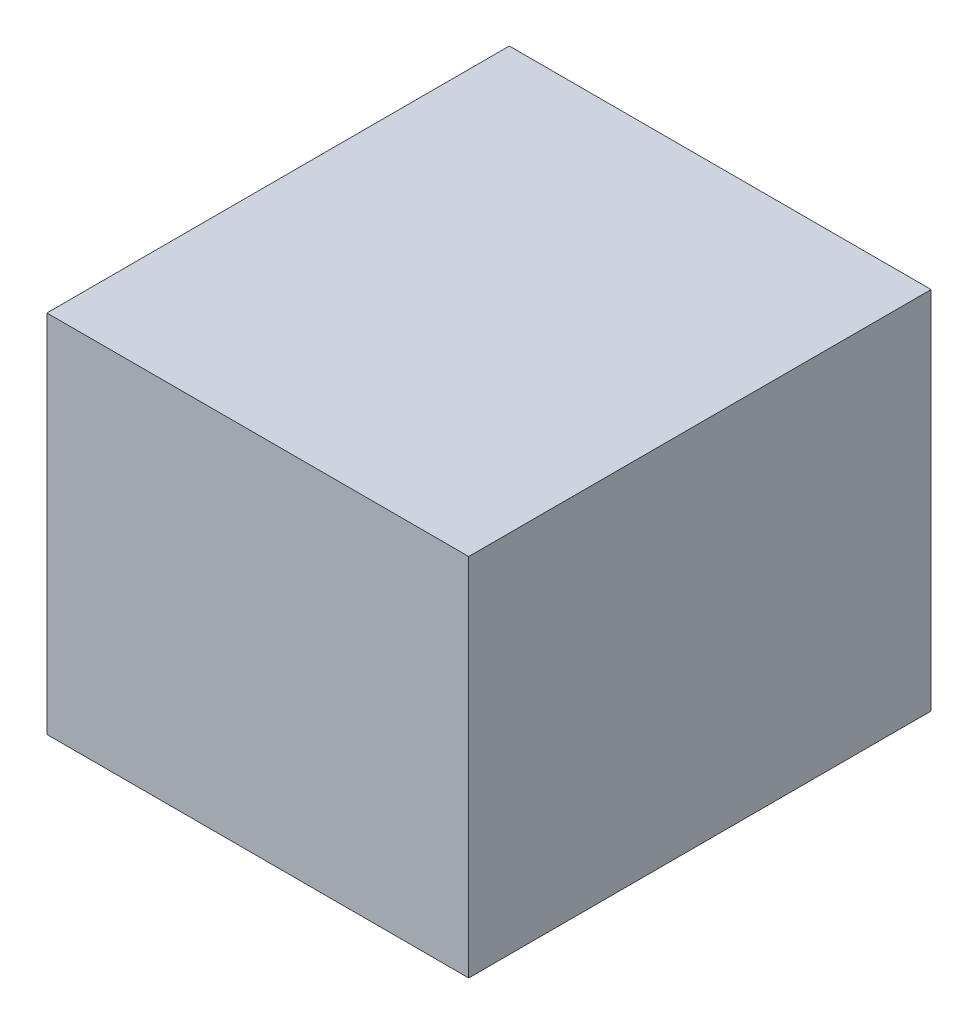
from build123d import *

# Parameters (mm, degrees)
SKETCH1_W           = 520
SKETCH1_H           = 450
BOSS_EXTRUDE1_DEPTH = 5
BOSS_EXTRUDE3_DEPTH = 560
SKETCH4_W           = 520
SKETCH4_H           = 450
BOSS_EXTRUDE4_DEPTH = 5
SKETCH5_W           = 520
SKETCH5_H           = 450
SKETCH5_W_2         = 510
SKETCH5_H_2         = 440
BOSS_EXTRUDE5_DEPTH = 100
SKETCH6_R           = 2.5
CUT_EXTRUDE1_DEPTH  = 10


with BuildPart() as part:
    # Sketch1 → Boss-Extrude1 (new body)
    with BuildSketch(Plane.XY):
        Rectangle(SKETCH1_W, SKETCH1_H)
    extrude(amount=BOSS_EXTRUDE1_DEPTH)

    # Sketch3 → Boss-Extrude3 (add)
    with BuildSketch(Plane(origin=(0, 0, 0), x_dir=(-1, 0, 0), z_dir=(0, 0, -1))):
        Polygon((260, 225), (-260, 225), (-260, -225), (-155, -225), (-155, -220), (-255, -220), (-255, 220), (255, 220), (255, -220), (155, -220), (155, -225), (260, -225), align=None)
    extrude(amount=BOSS_EXTRUDE3_DEPTH)

    # Sketch4 → Boss-Extrude4 (add)
    with BuildSketch(Plane(origin=(0, 0, -560), x_dir=(-1, 0, 0), z_dir=(0, 0, -1))):
        Rectangle(SKETCH4_W, SKETCH4_H)
    extrude(amount=BOSS_EXTRUDE4_DEPTH)

    # Sketch5 → Boss-Extrude5 (add)
    with BuildSketch(Plane.XY.offset(-560)):
        Rectangle(SKETCH5_W, SKETCH5_H)
        Rectangle(SKETCH5_W_2, SKETCH5_H_2, mode=Mode.SUBTRACT)
    extrude(amount=BOSS_EXTRUDE5_DEPTH)

    # Sketch6 → Cut-Extrude1 (cut)
    with BuildSketch(Plane.XZ.offset(225)):
        with Locations((-169.55, -10)):
            Circle(SKETCH6_R)
        with Locations((-169.55, -36)):
            Circle(SKETCH6_R)
        with Locations((-169.55, -450)):
            Circle(SKETCH6_R)
        with Locations((-169.55, -424)):
            Circle(SKETCH6_R)
    extrude(amount=-CUT_EXTRUDE1_DEPTH, mode=Mode.SUBTRACT)


solid = part.part
